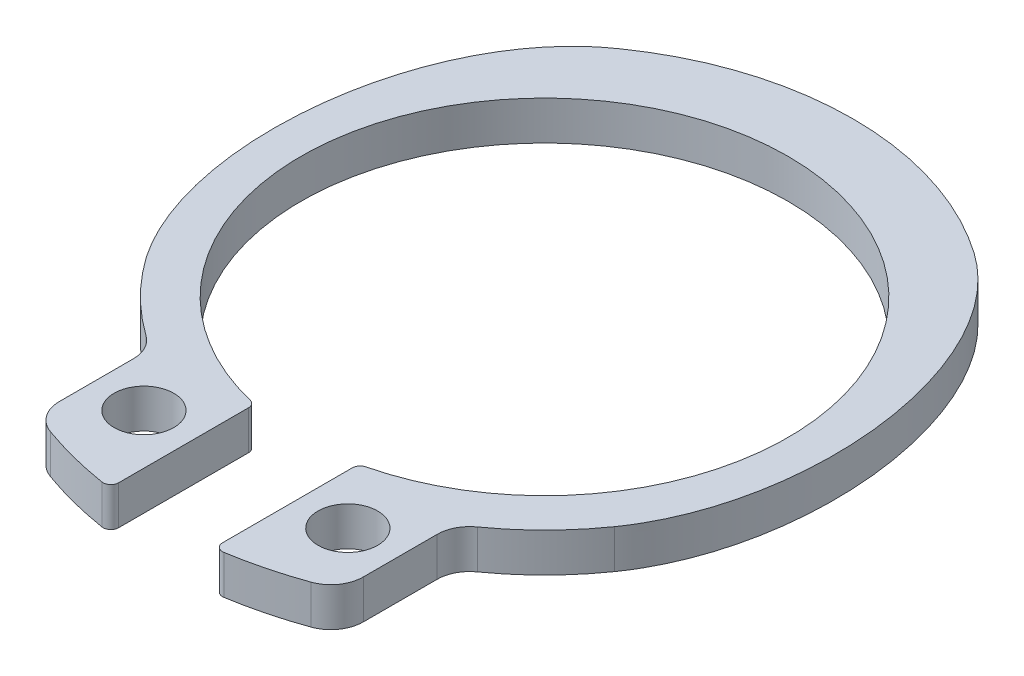
from build123d import *

# Parameters (mm, degrees)
SCHIZZO1_R                   = 0.458996056
ESTRUSIONE_ESTRUSIONE1_DEPTH = 0.6


with BuildPart() as part:
    # Schizzo1 → Estrusione-Estrusione1 (new body)
    with BuildSketch(Plane.XZ.offset(0.3)):
        with BuildLine():
            Line((-2.34, 5.13), (-2.34, 3.993043952))
            ThreePointArc((-2.34, 3.993043952), (-2.395647685, 3.763803858), (-2.550204082, 3.585590487))
            ThreePointArc((-2.550204082, 3.585590487), (-3.12270208, 3.099795432), (-3.604268995, 2.52373632))
            add(Edge.make_bspline(
                [(-3.604268995, 2.52373632), (-3.853924568, 2.156927576), (-4.029511845, 1.735833882), (-4.145169154, 1.307464944), (-4.308172181, 0.703737997), (-4.360675474, 0.06363484), (-4.320124497, -0.560393871), (-4.278553695, -1.200116418), (-4.137438556, -1.845937547), (-3.877676401, -2.432023456), (-3.723583884, -2.779693241), (-3.52331205, -3.113059535), (-3.273444303, -3.39973861), (-3.112104376, -3.58484766), (-2.9274837, -3.75281032), (-2.724488073, -3.89097221)],
                knots=[0, 0, 0, 0, 0.001331123, 0.001331123, 0.001331123, 0.003211952, 0.003211952, 0.003211952, 0.005142922, 0.005142922, 0.005142922, 0.006280106, 0.006280106, 0.006280106, 0.007010759, 0.007010759, 0.007010759, 0.007010759], degree=3))
            ThreePointArc((-2.724488073, -3.89097221), (0, -4.75), (2.724488073, -3.89097221))
            add(Edge.make_bspline(
                [(2.724488073, -3.89097221), (3.02256608, -3.682255743), (3.280103619, -3.409405395), (3.48806342, -3.110798992), (3.7651858, -2.712883068), (3.966732048, -2.257894847), (4.103489225, -1.792672996), (4.28909221, -1.161287017), (4.363995711, -0.488820559), (4.33114693, 0.168459959), (4.304204363, 0.707561374), (4.203554262, 1.252009555), (4.008527428, 1.755319372), (3.903955576, 2.02519013), (3.770275035, 2.286655125), (3.604268995, 2.52373632)],
                knots=[0, 0, 0, 0, 0.001091658, 0.001091658, 0.001091658, 0.002547666, 0.002547666, 0.002547666, 0.004529951, 0.004529951, 0.004529951, 0.006151973, 0.006151973, 0.006151973, 0.007014946, 0.007014946, 0.007014946, 0.007014946], degree=3))
            ThreePointArc((3.604268995, 2.52373632), (3.12270208, 3.099795432), (2.550204082, 3.585590487))
            ThreePointArc((2.550204082, 3.585590487), (2.395647685, 3.763803858), (2.34, 3.993043952))
            Line((2.34, 3.993043952), (2.34, 5.13))
            ThreePointArc((2.34, 5.13), (2.24890321, 5.417746703), (2.008807339, 5.600642202))
            ThreePointArc((2.008807339, 5.600642202), (1.480262865, 5.762926501), (0.938936535, 5.875448764))
            ThreePointArc((0.938936535, 5.875448764), (0.842129544, 5.848255068), (0.8, 5.756952319))
            Line((0.8, 5.756952319), (0.8, 3.759055732))
            ThreePointArc((0.8, 3.759055732), (0.825598581, 3.684972184), (0.891472868, 3.642495865))
            ThreePointArc((0.891472868, 3.642495865), (0, -3.75), (-0.891472868, 3.642495865))
            ThreePointArc((-0.891472868, 3.642495865), (-0.825598581, 3.684972184), (-0.8, 3.759055732))
            Line((-0.8, 3.759055732), (-0.8, 5.756952319))
            ThreePointArc((-0.8, 5.756952319), (-0.842129544, 5.848255068), (-0.938936535, 5.875448764))
            ThreePointArc((-0.938936535, 5.875448764), (-1.480262865, 5.762926501), (-2.008807339, 5.600642202))
            ThreePointArc((-2.008807339, 5.600642202), (-2.24890321, 5.417746703), (-2.34, 5.13))
        make_face()
        with Locations((1.57, 4.598363042)):
            Circle(SCHIZZO1_R, mode=Mode.SUBTRACT)
        with Locations((-1.57, 4.598363042)):
            Circle(SCHIZZO1_R, mode=Mode.SUBTRACT)
    extrude(amount=-ESTRUSIONE_ESTRUSIONE1_DEPTH)


solid = part.part
